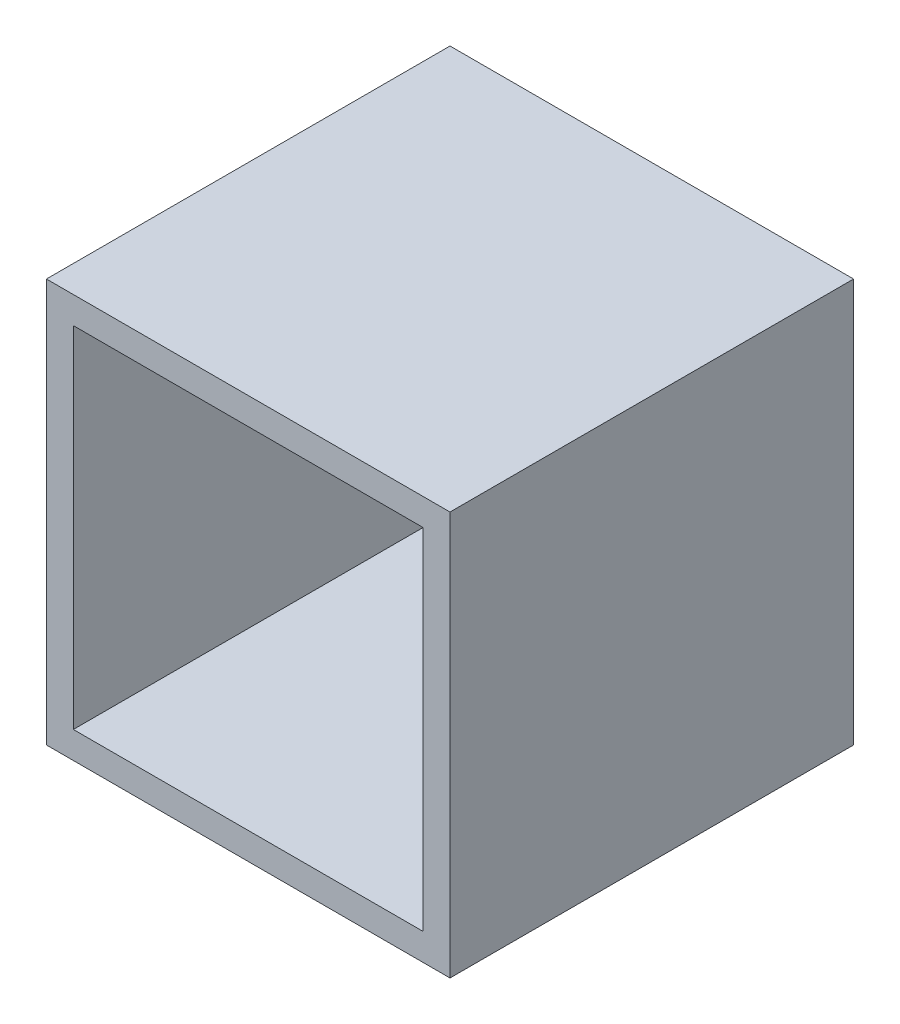
from build123d import *

# Parameters (mm, degrees)
SKETCH_1_W          = 30
SKETCH_1_H          = 30
EXTRUDE_1_DEPTH     = 30
SKETCH_2_W          = 26
SKETCH_2_H          = 26
CUT_EXTRUDE_2_DEPTH = 28


with BuildPart() as part:
    # 草图1 → 凸台-拉伸1 (new body)
    with BuildSketch(Plane.XY):
        with Locations((10.374514335, 12.518280569)):
            Rectangle(SKETCH_1_W, SKETCH_1_H)
    extrude(amount=EXTRUDE_1_DEPTH)

    # 草图2 → 切除-拉伸2 (cut)
    with BuildSketch(Plane.XY.offset(30)):
        with Locations((10.374514335, 12.518280569)):
            Rectangle(SKETCH_2_W, SKETCH_2_H)
    extrude(amount=-CUT_EXTRUDE_2_DEPTH, mode=Mode.SUBTRACT)


solid = part.part
